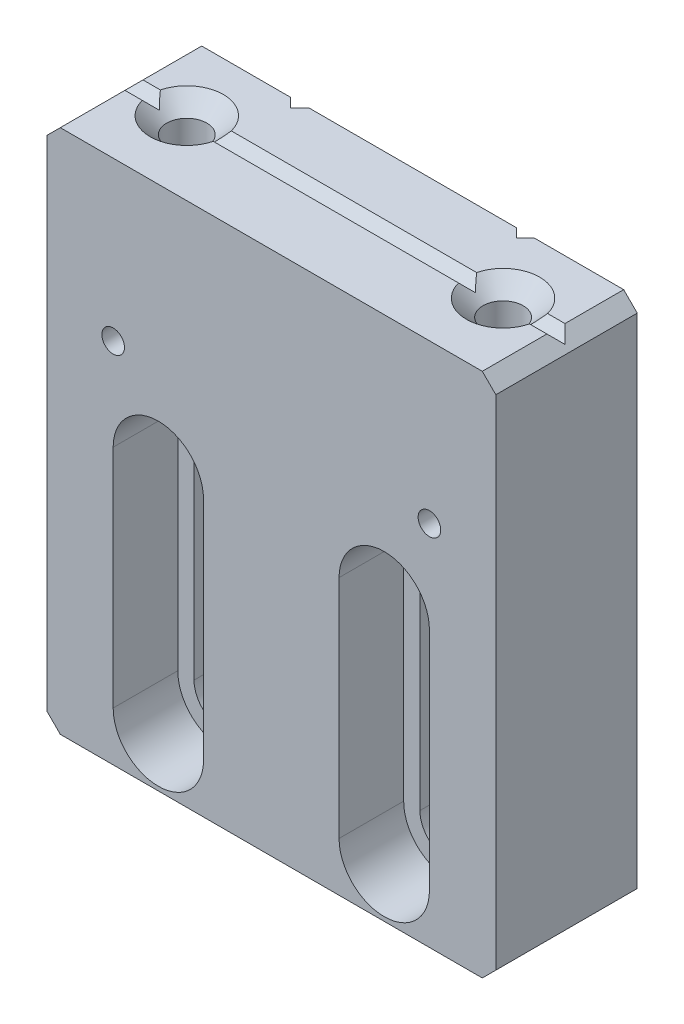
from build123d import *

# Parameters (mm, degrees)
SKETCH1_W                       = 25.2476
SKETCH1_H                       = 29.5402
BOSS_EXTRUDE1_DEPTH             = 7.9502
CHAMFER1_SIZE                   = 0.762
CUT_EXTRUDE1_DEPTH              = 30.5402
F_4_40_TAPPED_HOLE1_D           = 2.2606
F_4_40_TAPPED_HOLE1_DEPTH       = 9.5504
F_4_40_TAPPED_HOLE1_CSINK_D     = 4.1148
F_4_40_TAPPED_HOLE1_CSINK_ANGLE = 90
F_4_40_TAPPED_HOLE1_TIP         = 0.679152758
SKETCH6_R                       = 1.6256
SKETCH6_W                       = 3.2512
SKETCH6_H                       = 12.7
CUT_EXTRUDE3_DEPTH              = 8.9502
CUT_EXTRUDE4_DEPTH              = 3.6322
SKETCH11_R                      = 0.635
CUT_EXTRUDE5_DEPTH              = 8.9502
CUT_EXTRUDE7_DEPTH              = 13.6238
CUT_EXTRUDE7_DEPTH_BACK         = 13.6238


with BuildPart() as part:
    # Sketch1 → Boss-Extrude1 (new body)
    with BuildSketch(Plane.XY):
        Rectangle(SKETCH1_W, SKETCH1_H)
    extrude(amount=BOSS_EXTRUDE1_DEPTH)

    # Chamfer1
    chamfer1_edges = [part.edges().sort_by_distance(p)[0] for p in [
        (12.6238, -14.7701, 3.9751),
        (-12.6238, -14.7701, 3.9751),
        (-12.6238, 14.7701, 3.9751),
        (12.6238, 14.7701, 3.9751),
    ]]
    chamfer(chamfer1_edges, length=CHAMFER1_SIZE)

    # Sketch2 → Cut-Extrude1 (cut, through all)
    with BuildSketch(Plane(origin=(0, 14.7701, 0), x_dir=(1, 0, 0), z_dir=(0, 1, 0))):
        Polygon((-6.35, 0.508), (-6.858, 0), (-6.35, -0.508), (-5.842, 0), align=None)
        Polygon((5.842, 0), (6.35, -0.508), (6.858, 0), (6.35, 0.508), align=None)
    extrude(amount=-CUT_EXTRUDE1_DEPTH, mode=Mode.SUBTRACT)

    # #4-40 Tapped Hole1
    with Locations(Plane(origin=(0, 14.7701, 0), x_dir=(1, 0, 0), z_dir=(0, 1, 0))):
        with Locations((-8.89, -3.81), (8.89, -3.81)):
            CounterSinkHole(F_4_40_TAPPED_HOLE1_D / 2, F_4_40_TAPPED_HOLE1_CSINK_D / 2, depth=F_4_40_TAPPED_HOLE1_DEPTH, counter_sink_angle=F_4_40_TAPPED_HOLE1_CSINK_ANGLE)
            with Locations((0, 0, -(F_4_40_TAPPED_HOLE1_DEPTH + F_4_40_TAPPED_HOLE1_TIP / 2))):  # 118° drill point
                Cone(0, F_4_40_TAPPED_HOLE1_D / 2, F_4_40_TAPPED_HOLE1_TIP, mode=Mode.SUBTRACT)

    # Sketch6 → Cut-Extrude3 (cut, through all)
    with BuildSketch(Plane.XY.offset(7.9502)):
        with Locations((-6.35, 0.6985)):
            Circle(SKETCH6_R)
        with Locations((-6.35, -12.0015)):
            Circle(SKETCH6_R)
        with Locations((6.35, -12.0015)):
            Circle(SKETCH6_R)
        with Locations((6.35, 0.6985)):
            Circle(SKETCH6_R)
        with Locations((-6.35, -5.6515)):
            Rectangle(SKETCH6_W, SKETCH6_H)
        with Locations((6.35, -5.6515)):
            Rectangle(SKETCH6_W, SKETCH6_H)
    extrude(amount=-CUT_EXTRUDE3_DEPTH, mode=Mode.SUBTRACT)

    # Sketch8 → Cut-Extrude4 (cut)
    with BuildSketch(Plane.XY.offset(7.9502)):
        with BuildLine():
            ThreePointArc((8.89, 0.6985), (6.35, 3.2385), (3.81, 0.6985))
            Line((3.81, 0.6985), (3.81, -12.0015))
            ThreePointArc((3.81, -12.0015), (6.35, -14.5415), (8.89, -12.0015))
            Line((8.89, -12.0015), (8.89, 0.6985))
        make_face()
        with BuildLine():
            Line((4.7244, -12.0015), (4.7244, 0.6985))
            ThreePointArc((4.7244, 0.6985), (6.35, 2.3241), (7.9756, 0.6985))
            Line((7.9756, 0.6985), (7.9756, -12.0015))
            ThreePointArc((7.9756, -12.0015), (6.35, -13.6271), (4.7244, -12.0015))
        make_face(mode=Mode.SUBTRACT)
        with BuildLine():
            Line((-3.81, -12.0015), (-3.81, 0.6985))
            ThreePointArc((-3.81, 0.6985), (-6.35, 3.2385), (-8.89, 0.6985))
            Line((-8.89, 0.6985), (-8.89, -12.0015))
            ThreePointArc((-8.89, -12.0015), (-6.35, -14.5415), (-3.81, -12.0015))
        make_face()
        with BuildLine():
            ThreePointArc((-7.9756, 0.6985), (-6.35, 2.3241), (-4.7244, 0.6985))
            Line((-4.7244, 0.6985), (-4.7244, -12.0015))
            ThreePointArc((-4.7244, -12.0015), (-6.35, -13.6271), (-7.9756, -12.0015))
            Line((-7.9756, -12.0015), (-7.9756, 0.6985))
        make_face(mode=Mode.SUBTRACT)
    extrude(amount=-CUT_EXTRUDE4_DEPTH, mode=Mode.SUBTRACT)

    # Sketch11 → Cut-Extrude5 (cut, through all)
    with BuildSketch(Plane.XY.offset(7.9502)):
        with Locations((-8.89, 5.8674)):
            Circle(SKETCH11_R)
        with Locations((8.89, 5.8674)):
            Circle(SKETCH11_R)
    extrude(amount=-CUT_EXTRUDE5_DEPTH, mode=Mode.SUBTRACT)

    # Sketch15 → Cut-Extrude7 (cut, two sides)
    with BuildSketch(Plane(origin=(0, 0, 0), x_dir=(0, 0, -1), z_dir=(1, 0, 0))) as cut_extrude7_sk:
        Polygon((-53.679236414, 64.131336414), (-4.318, 14.7701), (-3.81, 14.2621), (-3.302, 14.7701), (46.059236414, 64.131336414), (46.059236414, 203.745996399), (-53.679236414, 203.745996399), align=None)
    extrude(amount=CUT_EXTRUDE7_DEPTH, mode=Mode.SUBTRACT)
    extrude(cut_extrude7_sk.sketch, amount=-CUT_EXTRUDE7_DEPTH_BACK, mode=Mode.SUBTRACT)


solid = part.part
